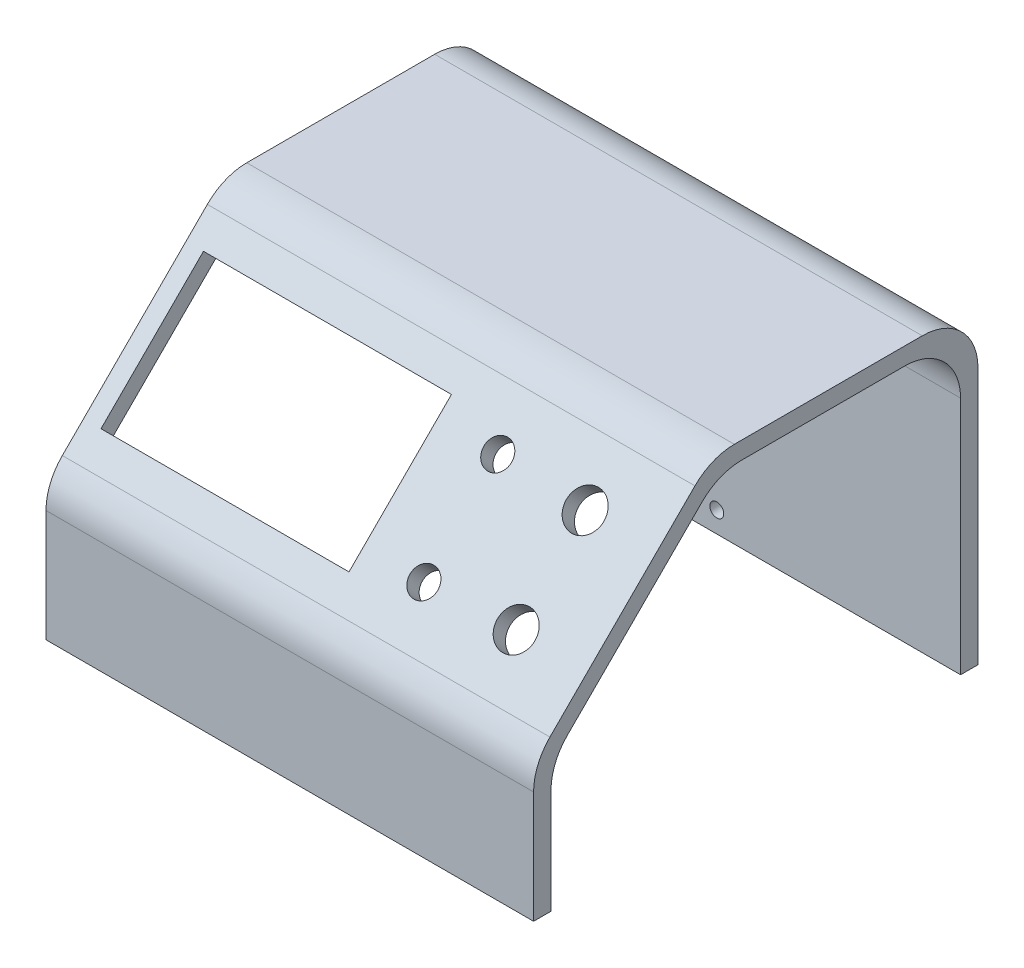
from build123d import *

# Parameters (mm, degrees)
BOSS_EXTRUDE1_DEPTH = 88.9
FILLET1_R           = 10.16
CUT_EXTRUDE1_REACH  = 76.71
SKETCH2_R           = 3.429
SKETCH2_R_2         = 2.54
SKETCH2_W           = 45.212
SKETCH2_H           = 26.416
CUT_EXTRUDE3_REACH  = 83.026
SKETCH4_R           = 1.27
SKETCH4_W           = 27.94
SKETCH4_H           = 25.4


with BuildPart() as part:
    # Sketch1 → Boss-Extrude1 (new body)
    with BuildSketch(Plane(origin=(0, 0, 0), x_dir=(0, 0, -1), z_dir=(1, 0, 0))):
        Polygon((0, 0), (0, 23.315129188), (30.532870812, 53.848), (74.676, 53.848), (74.676, 0), (77.851, 0), (77.851, 57.023), (29.217742751, 57.023), (-3.175, 24.630257249), (-3.175, 0), align=None)
    extrude(amount=BOSS_EXTRUDE1_DEPTH)

    # Fillet1
    fillet1_edges = [part.edges().sort_by_distance(p)[0] for p in [
        (44.45, 24.630257249, 3.175),
        (44.45, 57.023, -29.217742751),
        (44.45, 57.023, -77.851),
        (44.45, 53.848, -74.676),
        (44.45, 53.848, -30.532870812),
        (44.45, 23.315129188, 0),
    ]]
    fillet(fillet1_edges, radius=FILLET1_R)

    # Sketch2 → Cut-Extrude1 (cut, up to next)
    with BuildSketch(Plane(origin=(0, 13.902628624, 13.902628624), x_dir=(1, 0, 0), z_dir=(0, 0.707106781, 0.707106781)), mode=Mode.PRIVATE) as cut_extrude1_sk1:
        with Locations(Location((75.819, 46.966285953, 0), (0, 0, 270))):  # turned: the seam where the file's is
            Circle(SKETCH2_R)
    cut_extrude1_tool1 = extrude(cut_extrude1_sk1.sketch, amount=-CUT_EXTRUDE1_REACH, mode=Mode.PRIVATE) & part.part
    add(cut_extrude1_tool1.solids().sort_by_distance((75.819, 47.112808, -19.307551))[0], mode=Mode.SUBTRACT)
    # Sketch2 → Cut-Extrude1 (cut, up to next)
    with BuildSketch(Plane(origin=(0, 13.902628624, 13.902628624), x_dir=(1, 0, 0), z_dir=(0, 0.707106781, 0.707106781)), mode=Mode.PRIVATE) as cut_extrude1_sk2:
        with Locations(Location((75.819, 29.186285953, 0), (0, 0, 270))):  # turned: the seam where the file's is
            Circle(SKETCH2_R)
    cut_extrude1_tool2 = extrude(cut_extrude1_sk2.sketch, amount=-CUT_EXTRUDE1_REACH, mode=Mode.PRIVATE) & part.part
    add(cut_extrude1_tool2.solids().sort_by_distance((75.819, 34.540449, -6.735192))[0], mode=Mode.SUBTRACT)
    # Sketch2 → Cut-Extrude1 (cut, up to next)
    with BuildSketch(Plane(origin=(0, 13.902628624, 13.902628624), x_dir=(1, 0, 0), z_dir=(0, 0.707106781, 0.707106781)), mode=Mode.PRIVATE) as cut_extrude1_sk3:
        with Locations(Location((59.436, 47.601285953, 0), (0, 0, 270))):  # turned: the seam where the file's is
            Circle(SKETCH2_R_2)
    cut_extrude1_tool3 = extrude(cut_extrude1_sk3.sketch, amount=-CUT_EXTRUDE1_REACH, mode=Mode.PRIVATE) & part.part
    add(cut_extrude1_tool3.solids().sort_by_distance((59.436, 47.561821, -19.756563))[0], mode=Mode.SUBTRACT)
    # Sketch2 → Cut-Extrude1 (cut, up to next)
    with BuildSketch(Plane(origin=(0, 13.902628624, 13.902628624), x_dir=(1, 0, 0), z_dir=(0, 0.707106781, 0.707106781)), mode=Mode.PRIVATE) as cut_extrude1_sk4:
        with Locations(Location((59.436, 28.551285953, 0), (0, 0, 270))):  # turned: the seam where the file's is
            Circle(SKETCH2_R_2)
    cut_extrude1_tool4 = extrude(cut_extrude1_sk4.sketch, amount=-CUT_EXTRUDE1_REACH, mode=Mode.PRIVATE) & part.part
    add(cut_extrude1_tool4.solids().sort_by_distance((59.436, 34.091437, -6.286179))[0], mode=Mode.SUBTRACT)
    # Sketch2 → Cut-Extrude1 (cut, up to next)
    with BuildSketch(Plane(origin=(0, 13.902628624, 13.902628624), x_dir=(1, 0, 0), z_dir=(0, 0.707106781, 0.707106781)), mode=Mode.PRIVATE) as cut_extrude1_sk5:
        with Locations((25.781, 38.076285953)):
            Rectangle(SKETCH2_W, SKETCH2_H)
    cut_extrude1_tool5 = extrude(cut_extrude1_sk5.sketch, amount=-CUT_EXTRUDE1_REACH, mode=Mode.PRIVATE) & part.part
    add(cut_extrude1_tool5.solids().sort_by_distance((25.781, 40.826629, -13.021371))[0], mode=Mode.SUBTRACT)

    # Sketch4 → Cut-Extrude3 (cut, up to next)
    with BuildSketch(Plane(origin=(0, 0, -77.851), x_dir=(-1, 0, 0), z_dir=(0, 0, -1)), mode=Mode.PRIVATE) as cut_extrude3_sk1:
        with Locations((-44.45, 3.81)):
            Circle(SKETCH4_R)
    cut_extrude3_tool1 = extrude(cut_extrude3_sk1.sketch, amount=-CUT_EXTRUDE3_REACH, mode=Mode.PRIVATE) & part.part
    add(cut_extrude3_tool1.solids().sort_by_distance((44.45, 3.81, -77.851))[0], mode=Mode.SUBTRACT)
    # Sketch4 → Cut-Extrude3 (cut, up to next)
    with BuildSketch(Plane(origin=(0, 0, -77.851), x_dir=(-1, 0, 0), z_dir=(0, 0, -1)), mode=Mode.PRIVATE) as cut_extrude3_sk2:
        with Locations((-17.145, 30.988)):
            Rectangle(SKETCH4_W, SKETCH4_H)
    cut_extrude3_tool2 = extrude(cut_extrude3_sk2.sketch, amount=-CUT_EXTRUDE3_REACH, mode=Mode.PRIVATE) & part.part
    add(cut_extrude3_tool2.solids().sort_by_distance((17.145, 30.988, -77.851))[0], mode=Mode.SUBTRACT)


solid = part.part
